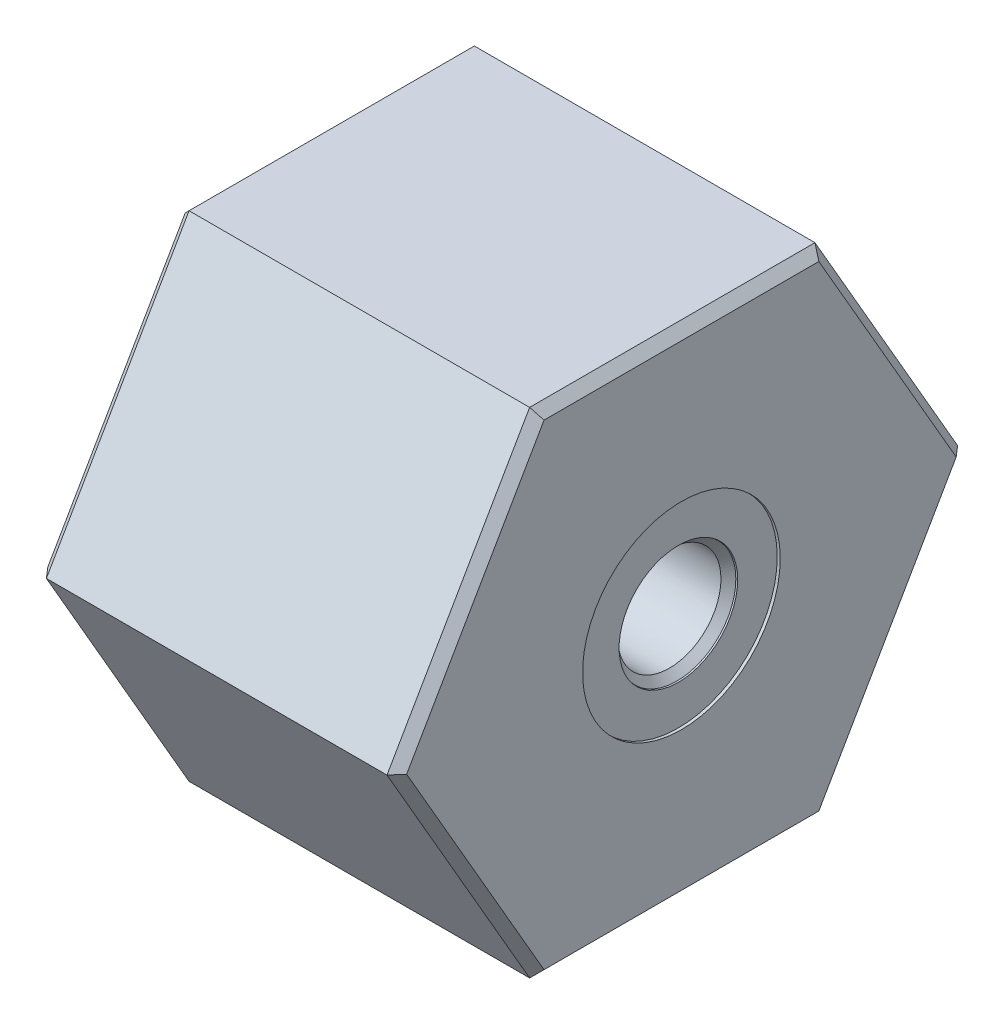
from build123d import *

# Parameters (mm, degrees)
EXTRUDE1_DEPTH = 29.972
CHAMFER1_SIZE  = 0.508
CHAMFER3_SIZE  = 0.762
CHAMFER4_SIZE  = 0.762
FILLET1_R      = 0.508


with BuildPart() as part:
    # Sketch1 → Extrude1 (new body)
    with BuildSketch(Plane(origin=(0, 0, 0), x_dir=(0, 0, -1), z_dir=(1, 0, 0))):
        Polygon((11.91506618, 20.6375), (-11.91506618, 20.6375), (-23.830132361, 0), (-11.91506618, -20.6375), (11.91506618, -20.6375), (23.830132361, 0), align=None)
    extrude(amount=EXTRUDE1_DEPTH)

    # Sketch2 → Cut-Revolve1 (revolve, cut)
    with BuildSketch(Plane.XY, mode=Mode.PRIVATE) as cut_revolve1_sk:
        Polygon((0, 16.7513), (0, 0), (29.972, 0), (29.972, 8.255), (29.718, 8.255), (29.718, 4.953), (29.591, 4.926005317), (28.970294683, 4.3053), (22.2504, 4.3053), (21.4884, 5.0673), (21.4884, 14.9352), (16.4592, 14.9352), (16.4592, 16.7513), align=None)
    revolve(cut_revolve1_sk.sketch.rotate(Axis((0, 0, 0), (1, 0, 0)), 270), axis=Axis((0, 0, 0), (1, 0, 0)), mode=Mode.SUBTRACT)  # turned: the seam where the file's is

    # Chamfer1
    chamfer1_edges = [part.edges().sort_by_distance(p)[0] for p in [
        (0, 0, 16.7513),
    ]]
    chamfer(chamfer1_edges, length=CHAMFER1_SIZE)

    # Chamfer3
    chamfer3_edges = [part.edges().sort_by_distance(p)[0] for p in [
        (0, -10.31875, -17.872599271),
        (0, -20.6375, 0),
        (0, -10.31875, 17.872599271),
        (0, 10.31875, 17.872599271),
        (0, 20.6375, 0),
        (0, 10.31875, -17.872599271),
    ]]
    chamfer(chamfer3_edges, length=CHAMFER3_SIZE)

    # Chamfer4
    chamfer4_edges = [part.edges().sort_by_distance(p)[0] for p in [
        (29.972, 10.31875, 17.872599271),
        (29.972, -10.31875, 17.872599271),
        (29.972, -20.6375, 0),
        (29.972, -10.31875, -17.872599271),
        (29.972, 10.31875, -17.872599271),
        (29.972, 20.6375, 0),
    ]]
    chamfer(chamfer4_edges, length=CHAMFER4_SIZE)

    # Fillet1
    fillet1_edges = [part.edges().sort_by_distance(p)[0] for p in [
        (16.4592, 0, 16.7513),
    ]]
    fillet(fillet1_edges, radius=FILLET1_R)


solid = part.part
